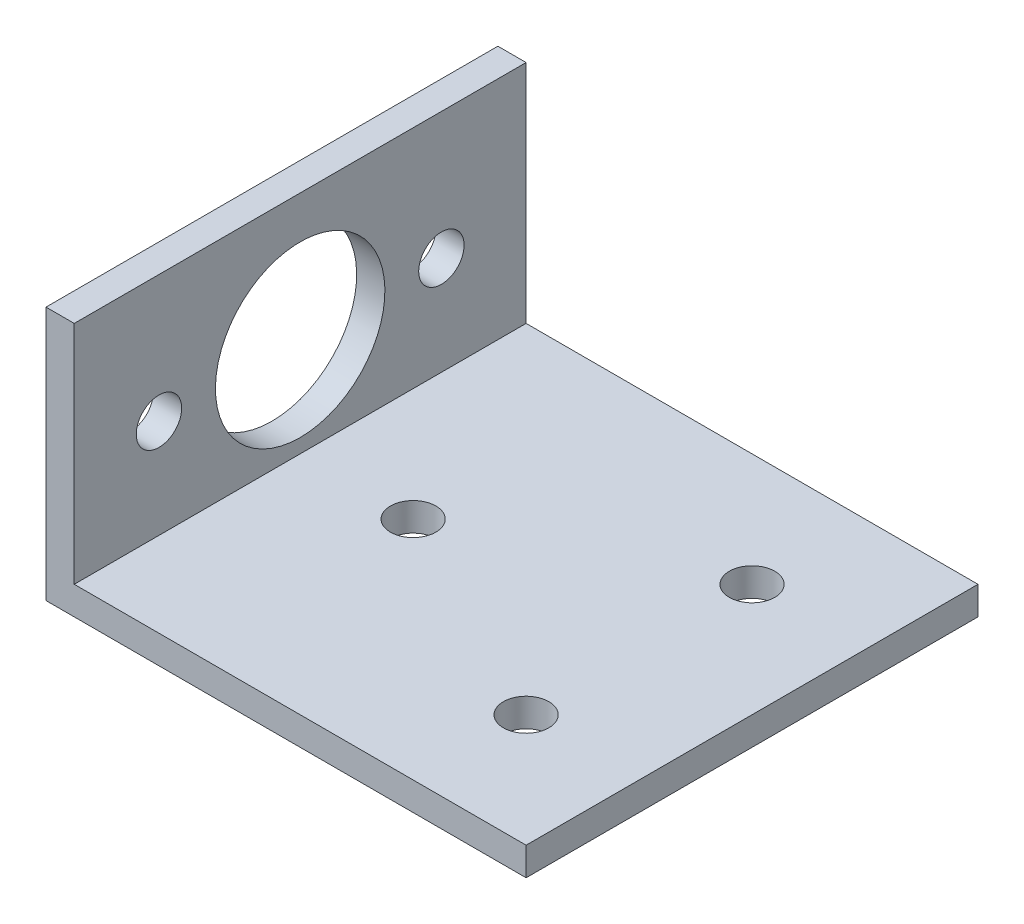
from build123d import *

# Parameters (mm, degrees)
BOSS_EXTRUDE1_DEPTH = 50.8
SKETCH2_R           = 9.525
SKETCH2_W           = 50.8
SKETCH2_H           = 22.225
CUT_EXTRUDE1_DEPTH  = 50.8
SKETCH3_R           = 2.5527
CUT_EXTRUDE2_DEPTH  = 50.8
SKETCH4_R           = 2.5527
CUT_EXTRUDE3_DEPTH  = 3.175


with BuildPart() as part:
    # Sketch1 → Boss-Extrude1 (new body)
    with BuildSketch(Plane.XY):
        Polygon((3.175, 50.8), (0, 50.8), (0, 0), (3.175, 0), (53.975, 0), (53.975, 3.175), (3.175, 3.175), align=None)
    extrude(amount=BOSS_EXTRUDE1_DEPTH)

    # Sketch2 → Cut-Extrude1 (cut)
    with BuildSketch(Plane.ZY):
        with Locations((25.4, 14.2875)):
            Circle(SKETCH2_R)
        with Locations((25.4, 39.6875)):
            Rectangle(SKETCH2_W, SKETCH2_H)
    extrude(amount=-CUT_EXTRUDE1_DEPTH, mode=Mode.SUBTRACT)

    # Sketch3 → Cut-Extrude2 (cut)
    with BuildSketch(Plane(origin=(0, 0, 0), x_dir=(-1, 0, 0), z_dir=(0, -1, 0))):
        with Locations((-15.875, -25.4)):
            Circle(SKETCH3_R)
        with Locations((-41.275, -38.1)):
            Circle(SKETCH3_R)
        with Locations((-41.275, -12.7)):
            Circle(SKETCH3_R)
    extrude(amount=-CUT_EXTRUDE2_DEPTH, mode=Mode.SUBTRACT)

    # Sketch4 → Cut-Extrude3 (cut)
    with BuildSketch(Plane.ZY):
        with Locations((9.525, 14.2875)):
            Circle(SKETCH4_R)
        with Locations((41.275, 14.2875)):
            Circle(SKETCH4_R)
    extrude(amount=-CUT_EXTRUDE3_DEPTH, mode=Mode.SUBTRACT)


solid = part.part
